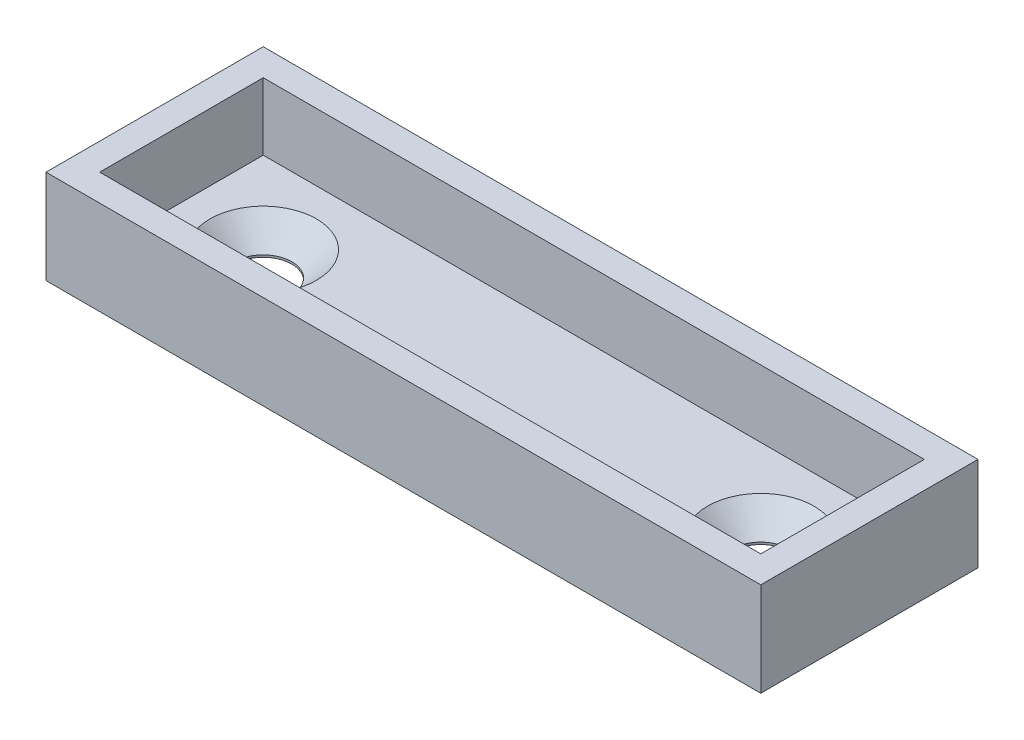
from build123d import *

# Parameters (mm, degrees)
SKETCH1_W           = 49.276
SKETCH1_H           = 12.192
BOSS_EXTRUDE1_DEPTH = 2
SKETCH2_W           = 53.276
SKETCH2_H           = 16.192
SKETCH2_W_2         = 49.276
SKETCH2_H_2         = 12.192
BOSS_EXTRUDE2_DEPTH = 7
SKETCH3_R           = 2.12725
CUT_EXTRUDE1_DEPTH  = 3
SKETCH5_W           = 25
SKETCH5_H           = 3.25
CUT_EXTRUDE2_DEPTH  = 0.6


with BuildPart() as part:
    # Sketch1 → Boss-Extrude1 (new body)
    with BuildSketch(Plane(origin=(0, 0, 0), x_dir=(1, 0, 0), z_dir=(0, 1, 0))):
        Rectangle(SKETCH1_W, SKETCH1_H)
    extrude(amount=BOSS_EXTRUDE1_DEPTH)

    # Sketch2 → Boss-Extrude2 (add)
    with BuildSketch(Plane(origin=(0, 0, 0), x_dir=(1, 0, 0), z_dir=(0, 1, 0))):
        Rectangle(SKETCH2_W, SKETCH2_H)
        Rectangle(SKETCH2_W_2, SKETCH2_H_2, mode=Mode.SUBTRACT)
    extrude(amount=BOSS_EXTRUDE2_DEPTH)

    # Sketch3 → Cut-Extrude1 (cut, through all)
    with BuildSketch(Plane(origin=(0, 2, 0), x_dir=(1, 0, 0), z_dir=(0, 1, 0))):
        with Locations((-18.542, 0)):
            Circle(SKETCH3_R)
    cut_extrude1 = extrude(amount=-CUT_EXTRUDE1_DEPTH, mode=Mode.SUBTRACT)

    # Sketch4 → Cut-Revolve1 (revolve, cut)
    with BuildSketch(Plane(origin=(0, 0, 0), x_dir=(-1, 0, 0), z_dir=(0, 0, -1))):
        Polygon((18.542, 1), (18.542, 2), (14.57325, 2), (18.542, -1.96875), align=None)
    cut_revolve1 = revolve(axis=Axis((-18.542, 2, 0), (0, 1, 0)), mode=Mode.SUBTRACT)

    # Mirror1: Cut-Extrude1, Cut-Revolve1 across plane
    add(cut_extrude1.mirror(Plane(origin=(0, 0, 0), x_dir=(0, 0, 1), z_dir=(1, 0, 0))), mode=Mode.SUBTRACT)
    add(cut_revolve1.mirror(Plane(origin=(0, 0, 0), x_dir=(0, 0, 1), z_dir=(1, 0, 0))), mode=Mode.SUBTRACT)

    # Sketch5 → Cut-Extrude2 (cut)
    with BuildSketch(Plane(origin=(0, 0, 0), x_dir=(-1, 0, 0), z_dir=(0, -1, 0))):
        with Locations((0, -5.471)):
            Rectangle(SKETCH5_W, SKETCH5_H)
        with Locations((0, 5.471)):
            Rectangle(SKETCH5_W, SKETCH5_H)
    extrude(amount=-CUT_EXTRUDE2_DEPTH, mode=Mode.SUBTRACT)


solid = part.part
